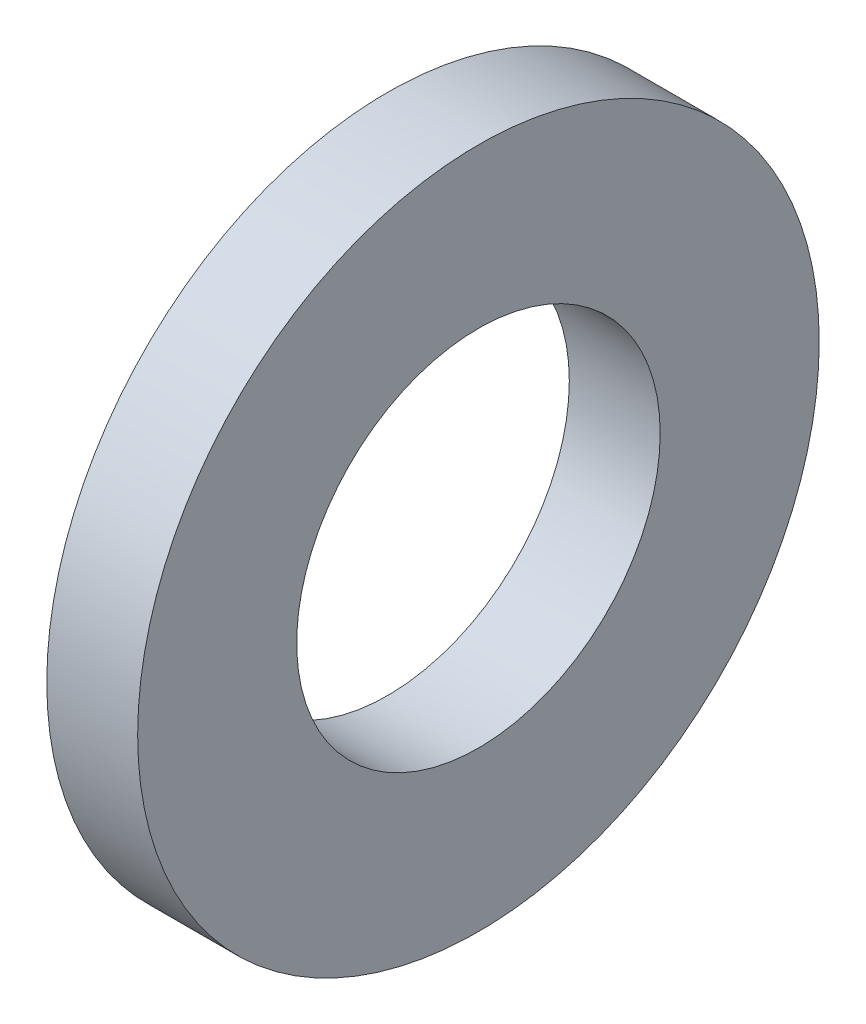
from build123d import *

# Parameters (mm, degrees)
SZKIC1_W = 1.6
SZKIC1_H = 2.8


with BuildPart() as part:
    # Szkic1 → Obrót1 (revolve)
    with BuildSketch(Plane.XY):
        with Locations((0.8, 4.6)):
            Rectangle(SZKIC1_W, SZKIC1_H)
    revolve(axis=Axis((0, 0, 0), (1, 0, 0)))


solid = part.part
